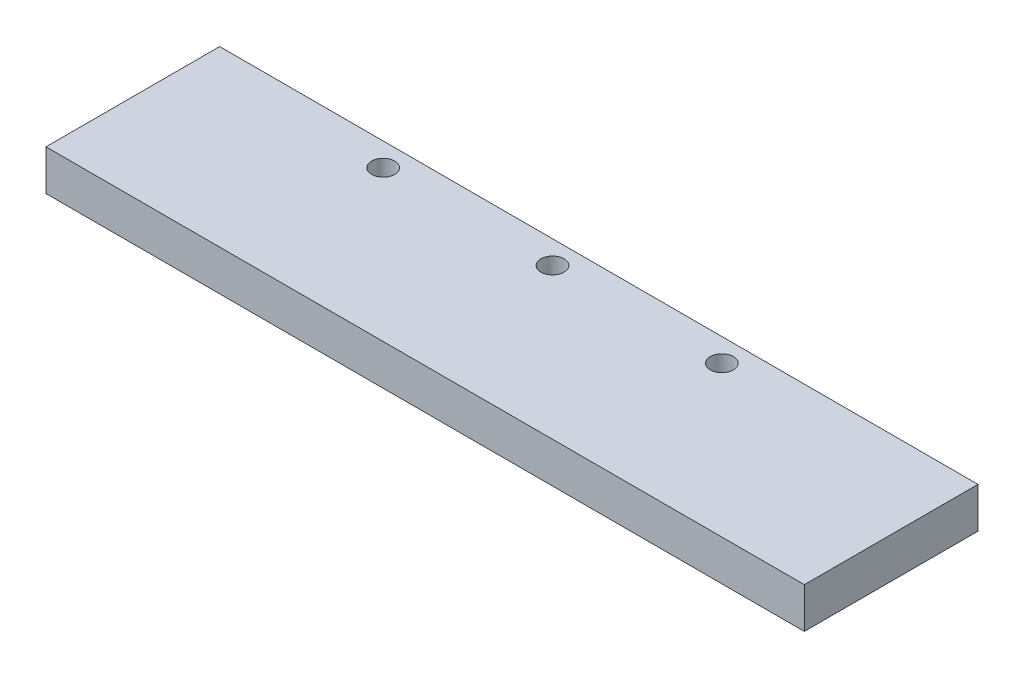
from build123d import *

# Parameters (mm, degrees)
SKETCH1_W           = 131
SKETCH1_H           = 30
BOSS_EXTRUDE1_DEPTH = 7
SKETCH2_R           = 2
CUT_EXTRUDE1_DEPTH  = 10


with BuildPart() as part:
    # Sketch1 → Boss-Extrude1 (new body)
    with BuildSketch(Plane(origin=(0, 0, 0), x_dir=(1, 0, 0), z_dir=(0, 1, 0))):
        with Locations((-37.010460251, 50.167364017)):
            Rectangle(SKETCH1_W, SKETCH1_H)
    extrude(amount=BOSS_EXTRUDE1_DEPTH)

    # Sketch2 → Cut-Extrude1 (cut)
    with BuildSketch(Plane.XZ):
        with Locations((-70.260460251, -61.167364017)):
            Circle(SKETCH2_R)
        with Locations((-41.010460251, -61.167364017)):
            Circle(SKETCH2_R)
        with Locations((-11.760460251, -61.167364017)):
            Circle(SKETCH2_R)
    extrude(amount=-CUT_EXTRUDE1_DEPTH, mode=Mode.SUBTRACT)


solid = part.part
